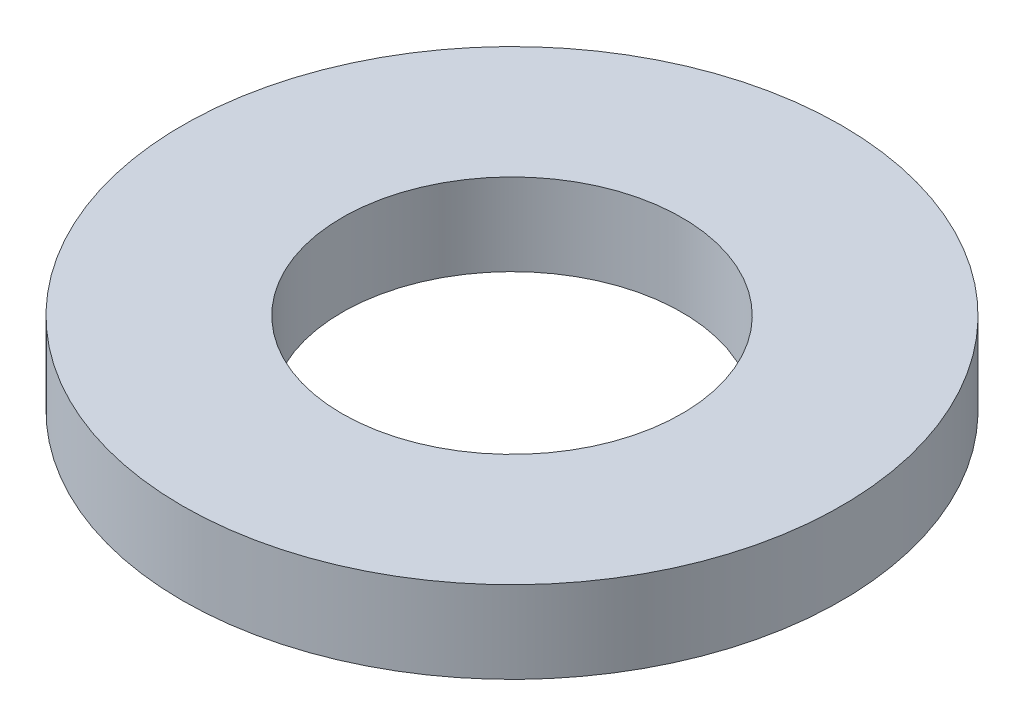
from build123d import *

# Parameters (mm, degrees)
SKETCH1_R                   = 2.8575
BOSS_EXTRUDE1_DEPTH         = 0.7112
F_32_0_116_DIAMETER_HOLE1_D = 2.9464


with BuildPart() as part:
    # Sketch1 → Boss-Extrude1 (new body)
    with BuildSketch(Plane(origin=(0, 0, 0), x_dir=(1, 0, 0), z_dir=(0, 1, 0))):
        Circle(SKETCH1_R)
    extrude(amount=BOSS_EXTRUDE1_DEPTH)

    # #32 (0.116) Diameter Hole1 (through all)
    with Locations(Plane(origin=(0, 0.7112, 0), x_dir=(1, 0, 0), z_dir=(0, 1, 0))):
        with Locations((0, 0)):
            Hole(F_32_0_116_DIAMETER_HOLE1_D / 2)


solid = part.part
